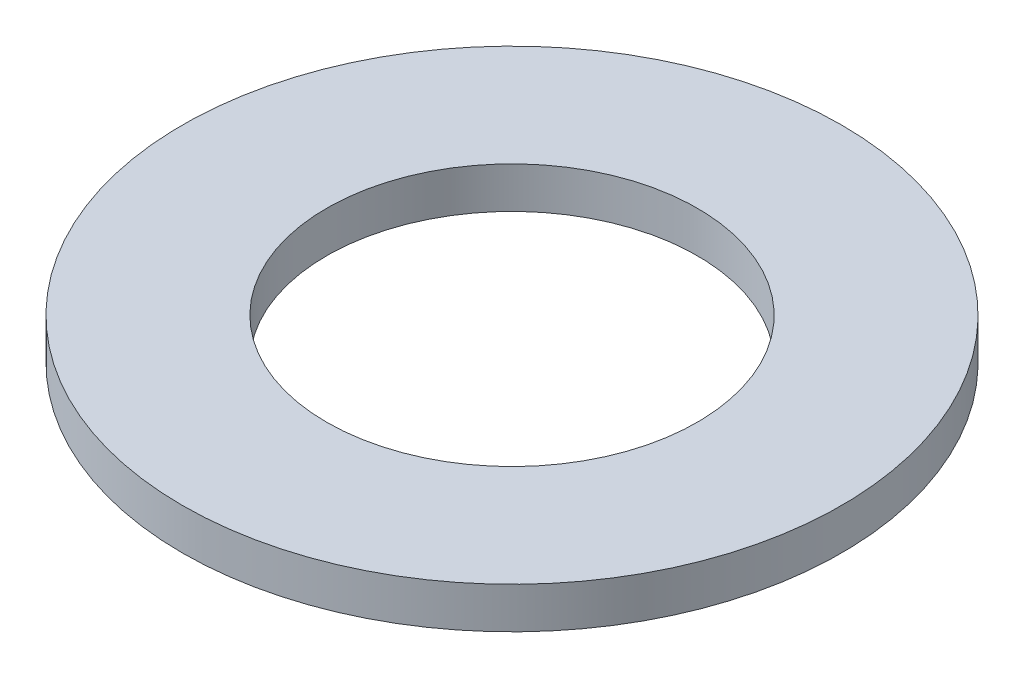
from build123d import *

# Parameters (mm, degrees)
CROQUIS1_R              = 8
CROQUIS1_R_2            = 4.5
SALIENTE_EXTRUIR1_DEPTH = 1


with BuildPart() as part:
    # Croquis1 → Saliente-Extruir1 (new body)
    with BuildSketch(Plane(origin=(0, 0, 0), x_dir=(1, 0, 0), z_dir=(0, 1, 0))):
        Circle(CROQUIS1_R)
        Circle(CROQUIS1_R_2, mode=Mode.SUBTRACT)
    extrude(amount=SALIENTE_EXTRUIR1_DEPTH)


solid = part.part
